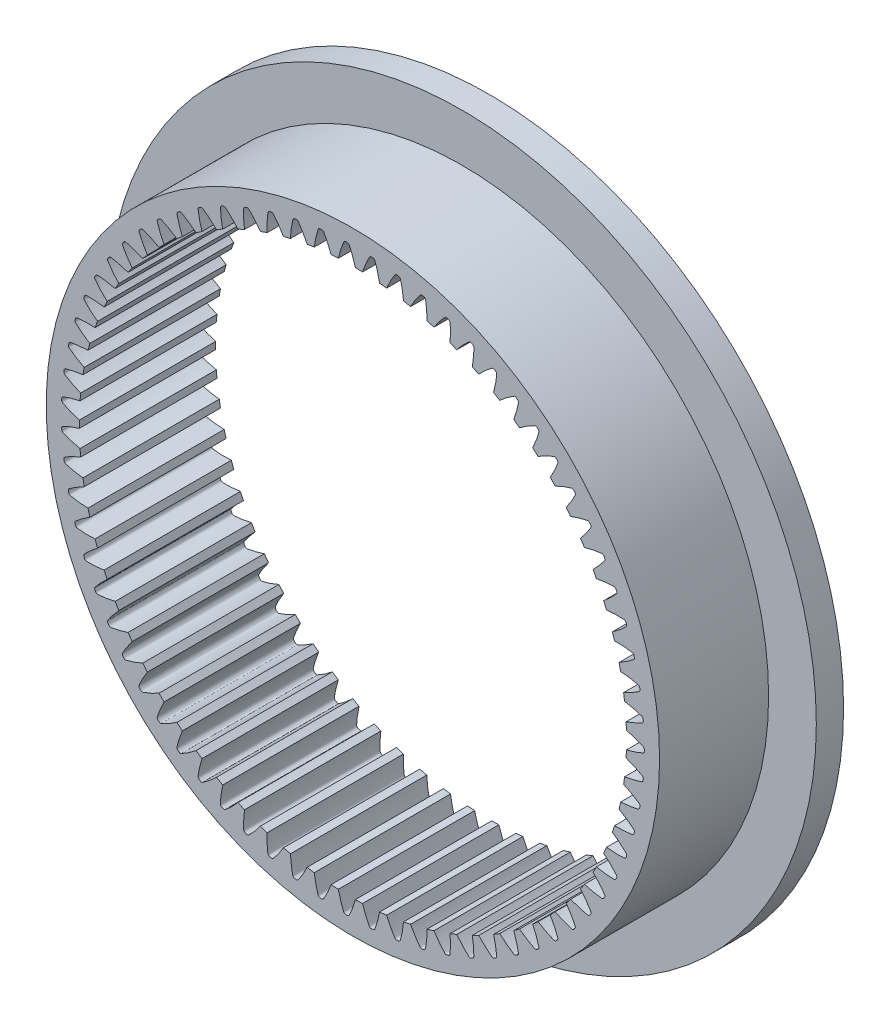
from build123d import *

# Parameters (mm, degrees)
SKETCHREVOLVERING_GEAR_FOLLOWER02_W       = 12.7
SKETCHREVOLVERING_GEAR_FOLLOWER02_H       = 12.605485554
TOOTHEXTRUDECUTRING_GEAR_FOLLOWER02_DEPTH = 6.35
PATTERNRING_GEAR_FOLLOWER02_COUNT         = 71
CUT_EXTRUDE1_START                        = -10.16
SKETCH1_R                                 = 38.1
SKETCH1_R_2                               = 28.575
CUT_EXTRUDE1_DEPTH                        = 10.16
SKETCH2_R                                 = 38.1
SKETCH2_R_2                               = 33.02
CUT_EXTRUDE2_DEPTH                        = 55.831064346


with BuildPart() as part:
    # SketchRevolveRing_Gear_Follower02 → Ring_Gear_Follower02 (revolve)
    with BuildSketch(Plane(origin=(0, 0, 0), x_dir=(0, 0, -1), z_dir=(1, 0, 0))):
        with Locations((0, 31.797257223)):
            Rectangle(SKETCHREVOLVERING_GEAR_FOLLOWER02_W, SKETCHREVOLVERING_GEAR_FOLLOWER02_H)
    revolve(axis=Axis((0, 0, 0), (0, 0, -1)))

    # SketchToothRing_Gear_Follower02 → ToothExtrudeCutRing_Gear_Follower02 (cut, symmetric)
    with BuildSketch(Plane.XY):
        with BuildLine():
            ThreePointArc((25.322927659, -0.82871153), (25.336484129, 0), (25.322927659, 0.82871153))
            add(Edge.make_bspline(
                [(25.322927659, 0.82871153), (25.411193227, 0.810779418), (25.548369787, 0.779641293), (25.73703866, 0.730716025), (25.893719775, 0.686526963), (26.060019661, 0.635793622), (26.235740614, 0.578122954), (26.420601194, 0.512958361), (26.614590985, 0.440440956), (26.816534891, 0.357921841), (26.965603298, 0.299305132), (27.053707916, 0.255658194), (27.07978715, 0.236202557), (27.102676224, 0.213703355), (27.122058774, 0.188078342), (27.137518064, 0.159938095), (27.152567702, 0.120273485), (27.157865815, 0.077173665), (27.157027264, 0.033782392), (27.157286624, 0), (27.157027264, -0.033782392), (27.157865815, -0.077173665), (27.152567702, -0.120273485), (27.137518064, -0.159938095), (27.122058774, -0.188078342), (27.102676224, -0.213703355), (27.07978715, -0.236202557), (27.053707916, -0.255658194), (26.965603298, -0.299305132), (26.816534891, -0.357921841), (26.614590985, -0.440440956), (26.420601194, -0.512958361), (26.235740614, -0.578122954), (26.060019661, -0.635793622), (25.893719775, -0.686526963), (25.73703866, -0.730716025), (25.548369787, -0.779641293), (25.411193227, -0.810779418), (25.322927659, -0.82871153)],
                knots=[0, 0, 0, 0, 0.063805266, 0.099630163, 0.138069903, 0.179124486, 0.222793912, 0.269078181, 0.317977293, 0.369491248, 0.423620045, 0.431437983, 0.438996188, 0.446554392, 0.454112596, 0.4616708, 0.469229004, 0.484048205, 0.492024109, 0.5, 0.507975891, 0.515951795, 0.530770996, 0.5383292, 0.545887404, 0.553445608, 0.561003812, 0.568562017, 0.576379955, 0.630508752, 0.682022707, 0.730921819, 0.777206088, 0.820875514, 0.861930097, 0.900369837, 0.936194734, 1, 1, 1, 1], degree=3))
        make_face()
    toothextrudecutring_gear_follower02 = extrude(amount=TOOTHEXTRUDECUTRING_GEAR_FOLLOWER02_DEPTH, both=True, mode=Mode.SUBTRACT)

    # PatternRing_Gear_Follower02: ToothExtrudeCutRing_Gear_Follower02 ×71 about axis
    patternring_gear_follower02_axis = Axis((0, 0, 55), (0, 0, -1))
    for i in range(1, PATTERNRING_GEAR_FOLLOWER02_COUNT):
        add(toothextrudecutring_gear_follower02.rotate(patternring_gear_follower02_axis, i * 360 / PATTERNRING_GEAR_FOLLOWER02_COUNT), mode=Mode.SUBTRACT)

    # Sketch1 → Cut-Extrude1 (cut)
    with BuildSketch(Plane.XY.offset(6.35).offset(CUT_EXTRUDE1_START)):
        Circle(SKETCH1_R)
        Circle(SKETCH1_R_2, mode=Mode.SUBTRACT)
    extrude(amount=CUT_EXTRUDE1_DEPTH, mode=Mode.SUBTRACT)

    # Sketch2 → Cut-Extrude2 (cut, through all)
    with BuildSketch(Plane.XY.offset(-3.81)):
        Circle(SKETCH2_R)
        Circle(SKETCH2_R_2, mode=Mode.SUBTRACT)
    extrude(amount=-CUT_EXTRUDE2_DEPTH, mode=Mode.SUBTRACT)


solid = part.part
